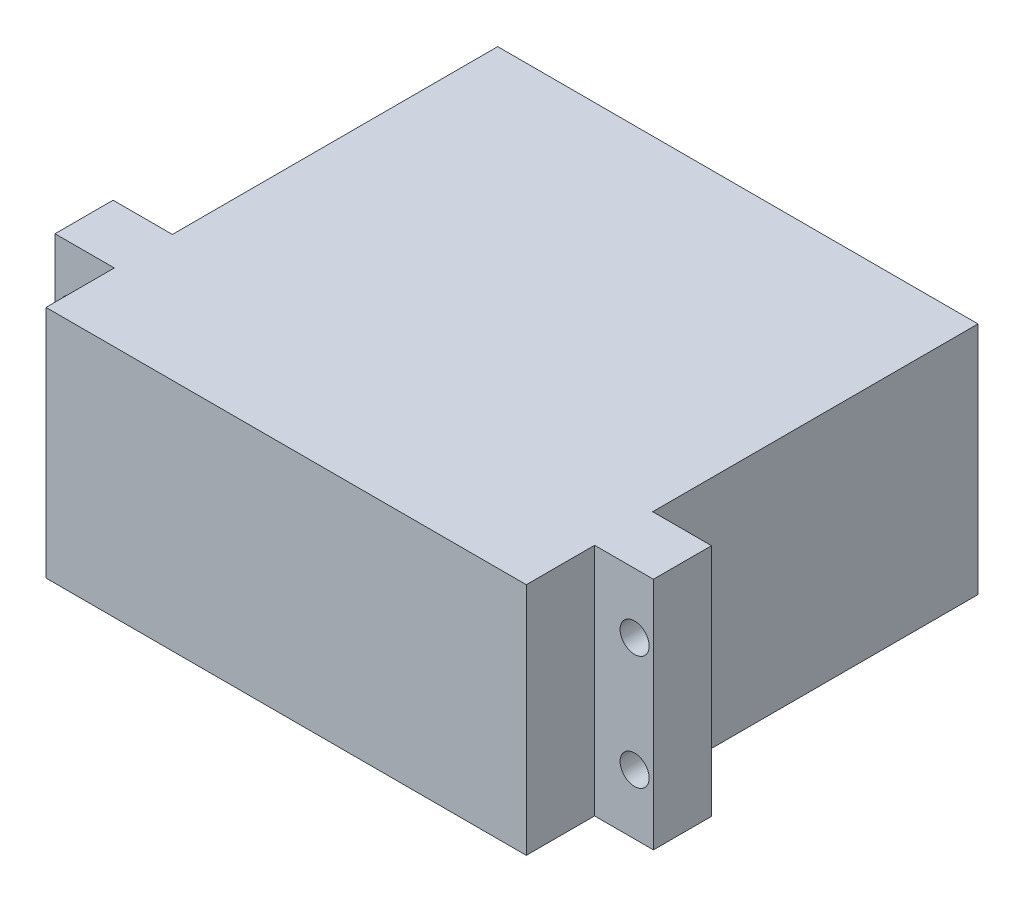
from build123d import *

# Parameters (mm, degrees)
SKETCH1_W           = 42
SKETCH1_H           = 20.5
BOSS_EXTRUDE1_DEPTH = 39.5
SKETCH2_W           = 5.185118418
SKETCH2_H           = 20.5
SKETCH2_R           = 1.27
SKETCH2_W_2         = 5.144602193
BOSS_EXTRUDE2_DEPTH = 5.08


with BuildPart() as part:
    # Sketch1 → Boss-Extrude1 (new body)
    with BuildSketch(Plane.XY):
        with Locations((21, 10.25)):
            Rectangle(SKETCH1_W, SKETCH1_H)
    extrude(amount=BOSS_EXTRUDE1_DEPTH)

    # Sketch2 → Boss-Extrude2 (add)
    with BuildSketch(Plane(origin=(0, 0, 28.448), x_dir=(-1, 0, 0), z_dir=(0, 0, -1))):
        with Locations((2.592559209, 10.25)):
            Rectangle(SKETCH2_W, SKETCH2_H)
        with Locations((3.5, 5.25)):
            Circle(SKETCH2_R, mode=Mode.SUBTRACT)
        with Locations((3.5, 15.25)):
            Circle(SKETCH2_R, mode=Mode.SUBTRACT)
        with Locations((-44.572301096, 10.25)):
            Rectangle(SKETCH2_W_2, SKETCH2_H)
        with Locations((-45.5, 5.25)):
            Circle(SKETCH2_R, mode=Mode.SUBTRACT)
        with Locations((-45.5, 15.25)):
            Circle(SKETCH2_R, mode=Mode.SUBTRACT)
    extrude(amount=-BOSS_EXTRUDE2_DEPTH)


solid = part.part
